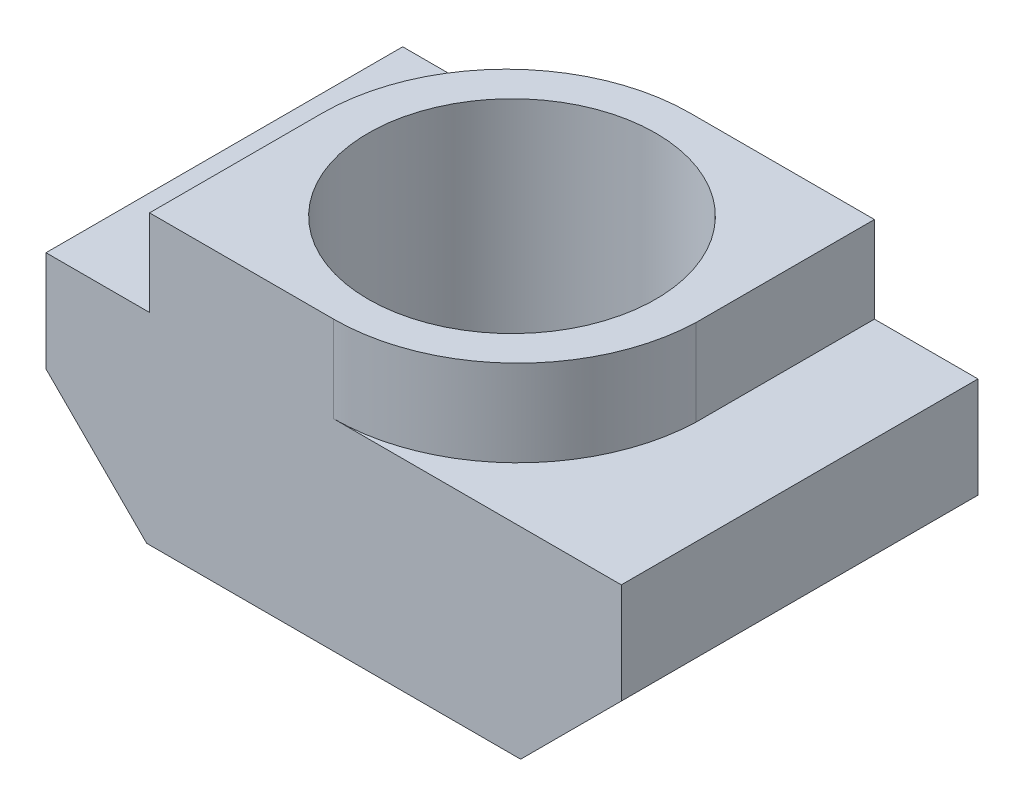
from build123d import *

# Parameters (mm, degrees)
BOSS_EXTRUDE1_DEPTH = 6.2
SKETCH2_R           = 2.5
CUT_EXTRUDE1_DEPTH  = 8
CUT_EXTRUDE2_DEPTH  = 1.5


with BuildPart() as part:
    # Sketch1 → Boss-Extrude1 (new body)
    with BuildSketch(Plane.XY):
        Polygon((0, 5), (0, 0), (3.25, 0), (5, 1.75), (5, 3.5), (3.2, 3.5), (3.2, 5), align=None)
    extrude(amount=BOSS_EXTRUDE1_DEPTH)

    # Mirror1: part across plane


with BuildPart() as part_1:
    add(part.part)
    add(part.part.mirror(Plane(origin=(0, 0, 0), x_dir=(0, 0, 1), z_dir=(1, 0, 0))))

    # Sketch2 → Cut-Extrude1 (cut)
    with BuildSketch(Plane(origin=(0, 5, 0), x_dir=(1, 0, 0), z_dir=(0, 1, 0))):
        with Locations((0, -3.1)):
            Circle(SKETCH2_R)
    extrude(amount=-CUT_EXTRUDE1_DEPTH, mode=Mode.SUBTRACT)

    # Sketch3 → Cut-Extrude2 (cut)
    with BuildSketch(Plane(origin=(0, 5, 0), x_dir=(1, 0, 0), z_dir=(0, 1, 0))):
        with BuildLine():
            ThreePointArc((3.2, -3.1), (2.227666941, -5.297914262), (0, -6.2))
            Line((0, -6.2), (3.2, -6.2))
            Line((3.2, -6.2), (3.2, -3.1))
        make_face()
        with BuildLine():
            Line((-3.2, 0), (-3.2, -3.2))
            ThreePointArc((-3.2, -3.2), (-2.2627417, -0.9372583), (0, 0))
            Line((0, 0), (-3.2, 0))
        make_face()
    extrude(amount=-CUT_EXTRUDE2_DEPTH, mode=Mode.SUBTRACT)


solid = part_1.part
